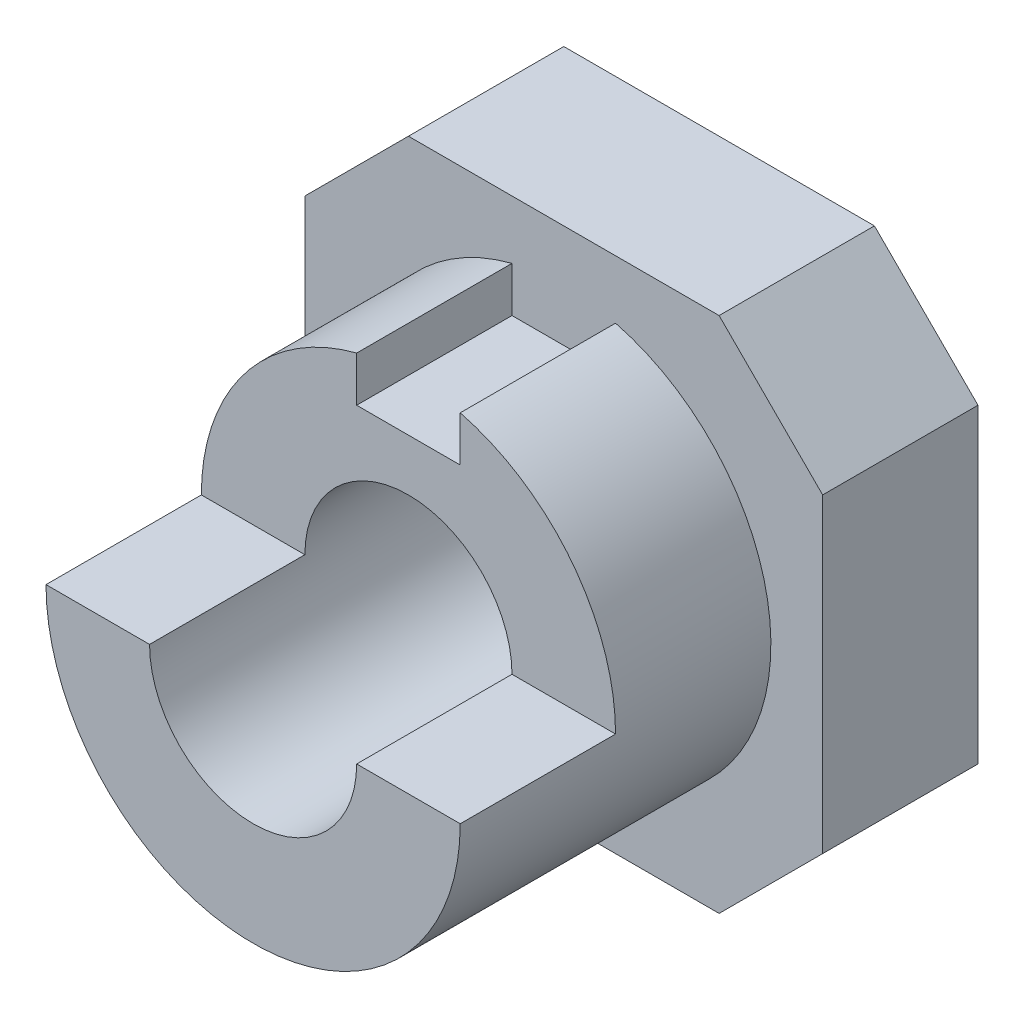
from build123d import *

# Parameters (mm, degrees)
SKETCH2_R           = 2
BOSS_EXTRUDE1_DEPTH = 3
SKETCH3_R           = 2
BOSS_EXTRUDE2_DEPTH = 6
SKETCH4_W           = 8
SKETCH4_H           = 4.603389885
CUT_EXTRUDE1_DEPTH  = 3


with BuildPart() as part:
    # Sketch2 → Boss-Extrude1 (new body)
    with BuildSketch(Plane.XY):
        Polygon((-5, 3), (-3, 5), (3, 5), (5, 3), (5, -3), (3, -5), (-3, -5), (-5, -3), align=None)
        Circle(SKETCH2_R, mode=Mode.SUBTRACT)
    extrude(amount=BOSS_EXTRUDE1_DEPTH)

    # Sketch3 → Boss-Extrude2 (add)
    with BuildSketch(Plane.XY.offset(3)):
        with BuildLine():
            Line((1, 3), (-1, 3))
            Line((-1, 3), (-1, 3.872983346))
            ThreePointArc((-1, 3.872983346), (0, -4), (1, 3.872983346))
            Line((1, 3.872983346), (1, 3))
        make_face()
        Circle(SKETCH3_R, mode=Mode.SUBTRACT)
    extrude(amount=BOSS_EXTRUDE2_DEPTH)

    # Sketch4 → Cut-Extrude1 (cut)
    with BuildSketch(Plane.XY.offset(9)):
        with Locations((0, 2.301694943)):
            Rectangle(SKETCH4_W, SKETCH4_H)
    extrude(amount=-CUT_EXTRUDE1_DEPTH, mode=Mode.SUBTRACT)


solid = part.part
